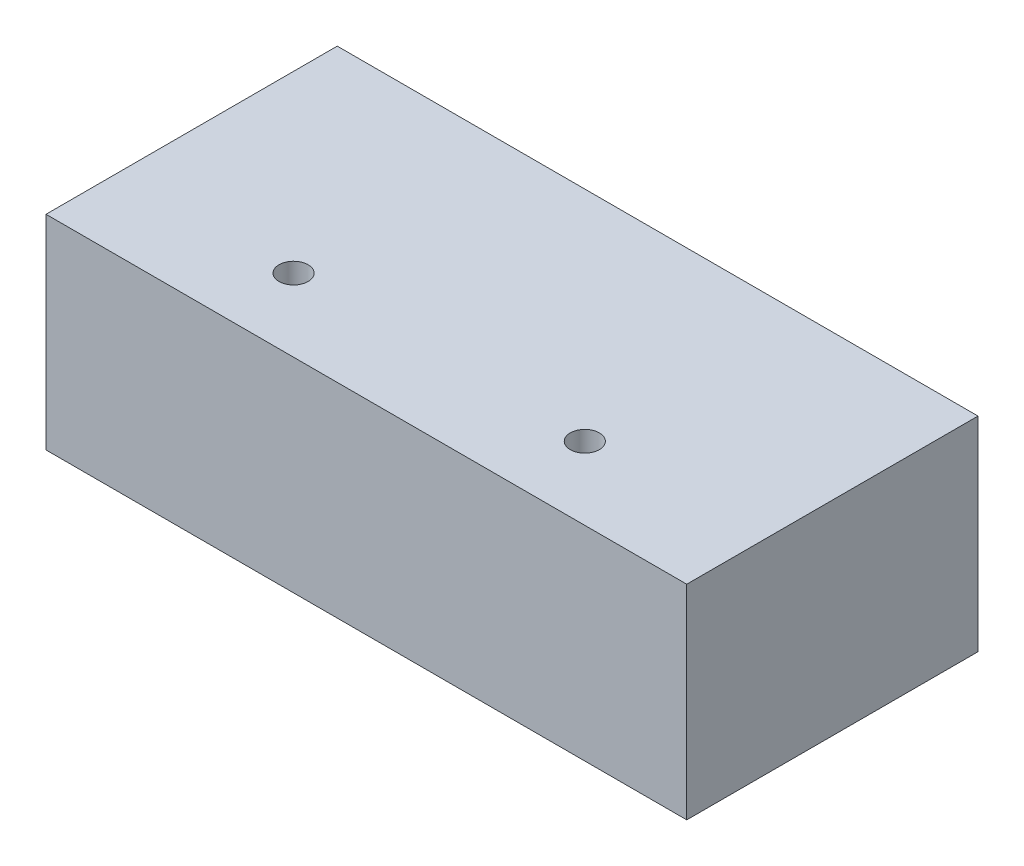
from build123d import *

# Parameters (mm, degrees)
CROQUIS1_W              = 52.8
CROQUIS1_H              = 16.82
SALIENTE_EXTRUIR1_DEPTH = 30
CROQUIS2_R              = 1.2
CORTAR_EXTRUIR1_DEPTH   = 20
CROQUIS3_R              = 1.2
CORTAR_EXTRUIR2_DEPTH   = 10
CROQUIS4_W              = 52.8
CROQUIS4_H              = 16.82
CORTAR_EXTRUIR3_DEPTH   = 6


with BuildPart() as part:
    # Croquis1 → Saliente-Extruir1 (new body)
    with BuildSketch(Plane.XY):
        Rectangle(CROQUIS1_W, CROQUIS1_H)
    extrude(amount=SALIENTE_EXTRUIR1_DEPTH)

    # Croquis2 → Cortar-Extruir1 (cut)
    with BuildSketch(Plane(origin=(0, 8.41, 0), x_dir=(1, 0, 0), z_dir=(0, 1, 0))):
        with Locations((-12, -18)):
            Circle(CROQUIS2_R)
        with Locations((12, -18)):
            Circle(CROQUIS2_R)
    extrude(amount=-CORTAR_EXTRUIR1_DEPTH, mode=Mode.SUBTRACT)

    # Croquis3 → Cortar-Extruir2 (cut)
    with BuildSketch(Plane.XY):
        with Locations((18.6, 0)):
            Circle(CROQUIS3_R)
        with Locations((7, 0)):
            Circle(CROQUIS3_R)
        with Locations((-7, 0)):
            Circle(CROQUIS3_R)
        with Locations((-18.6, 0)):
            Circle(CROQUIS3_R)
    extrude(amount=CORTAR_EXTRUIR2_DEPTH, mode=Mode.SUBTRACT)

    # Croquis4 → Cortar-Extruir3 (cut)
    with BuildSketch(Plane.XY.offset(30)):
        Rectangle(CROQUIS4_W, CROQUIS4_H)
    extrude(amount=-CORTAR_EXTRUIR3_DEPTH, mode=Mode.SUBTRACT)


solid = part.part
